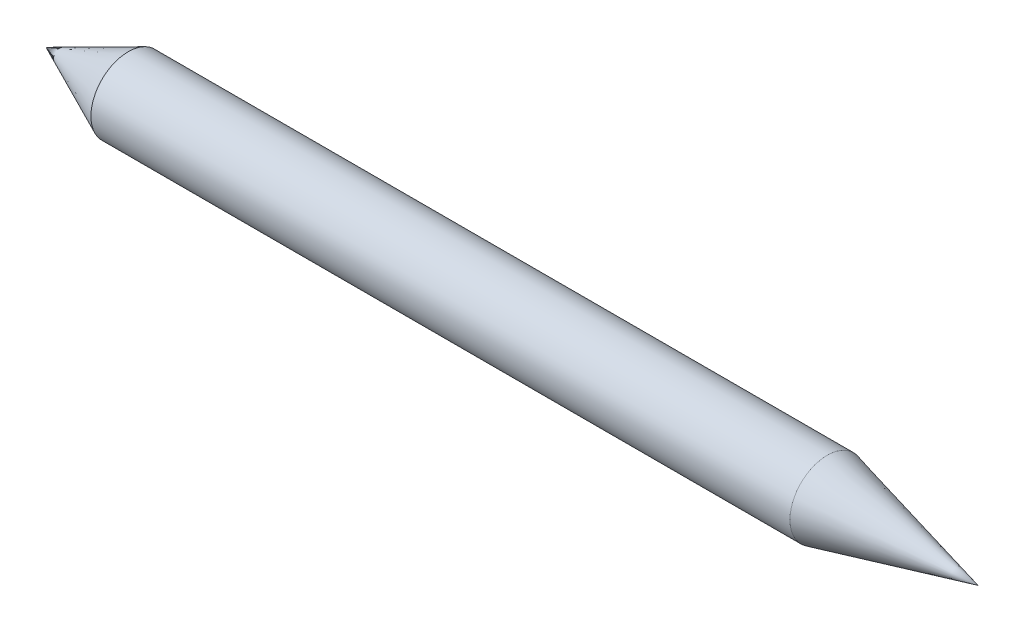
from build123d import *


with BuildPart() as part:
    # Croquis1 → Revolución2 (revolve)
    with BuildSketch(Plane.XY):
        Polygon((-79.053152984, 7.18483977), (120.946847016, 7.18483977), (88.590740478, 15.18483977), (-61.409259522, 15.18483977), align=None)
    revolve(axis=Axis((-79.053152984, 7.18483977, 0), (1, 0, 0)))


solid = part.part
